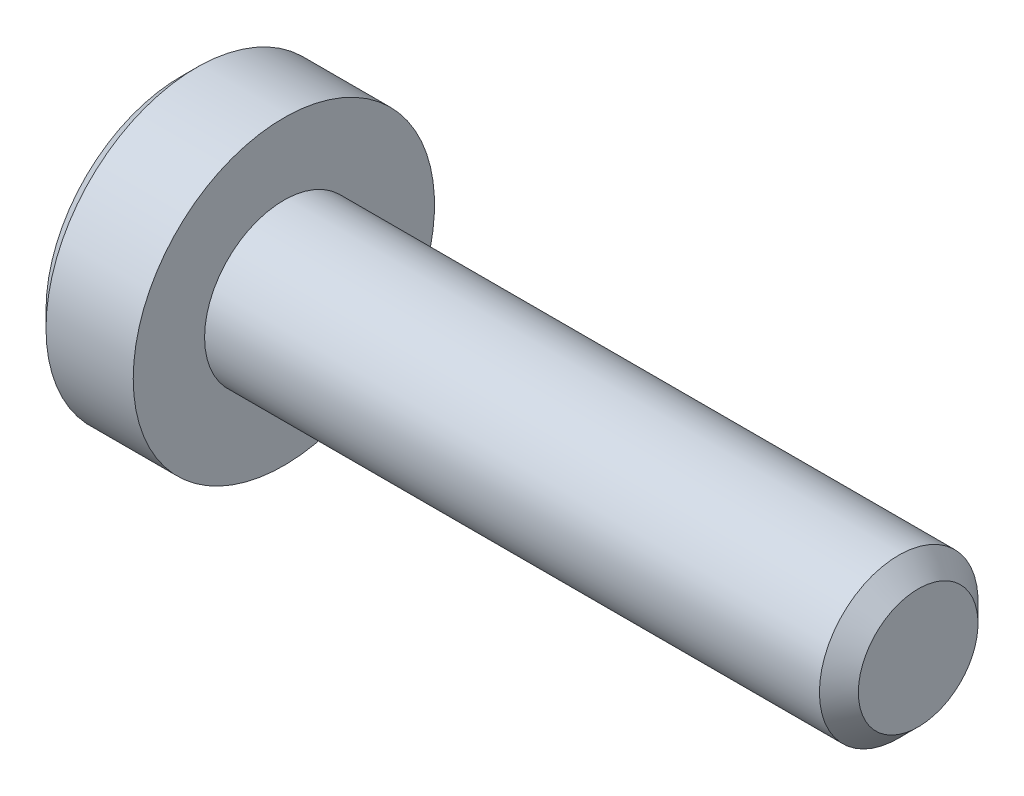
from build123d import *

# Parameters (mm, degrees)
CUT_EXTRUDE1_DEPTH = 0.7


with BuildPart() as part:
    # Sketch1 → Revolve1 (revolve)
    with BuildSketch(Plane.XY):
        Polygon((-1.3, 0), (-1.3, 1.7), (-1.1, 1.9), (0, 1.9), (0, 1), (7.7545, 1), (8, 0.7545), (8, 0), align=None)
    revolve(axis=Axis((8, 0, 0), (-1, 0, 0)))

    # Sketch2 → Cut-Extrude1 (cut)
    with BuildSketch(Plane(origin=(-1.3, 0, 0), x_dir=(0, 0, -1), z_dir=(1, 0, 0))):
        Polygon((-0.65, -0.375277675), (0, -0.75055535), (0.65, -0.375277675), (0.65, 0.375277675), (0, 0.75055535), (-0.65, 0.375277675), align=None)
    extrude(amount=CUT_EXTRUDE1_DEPTH, mode=Mode.SUBTRACT)


solid = part.part
